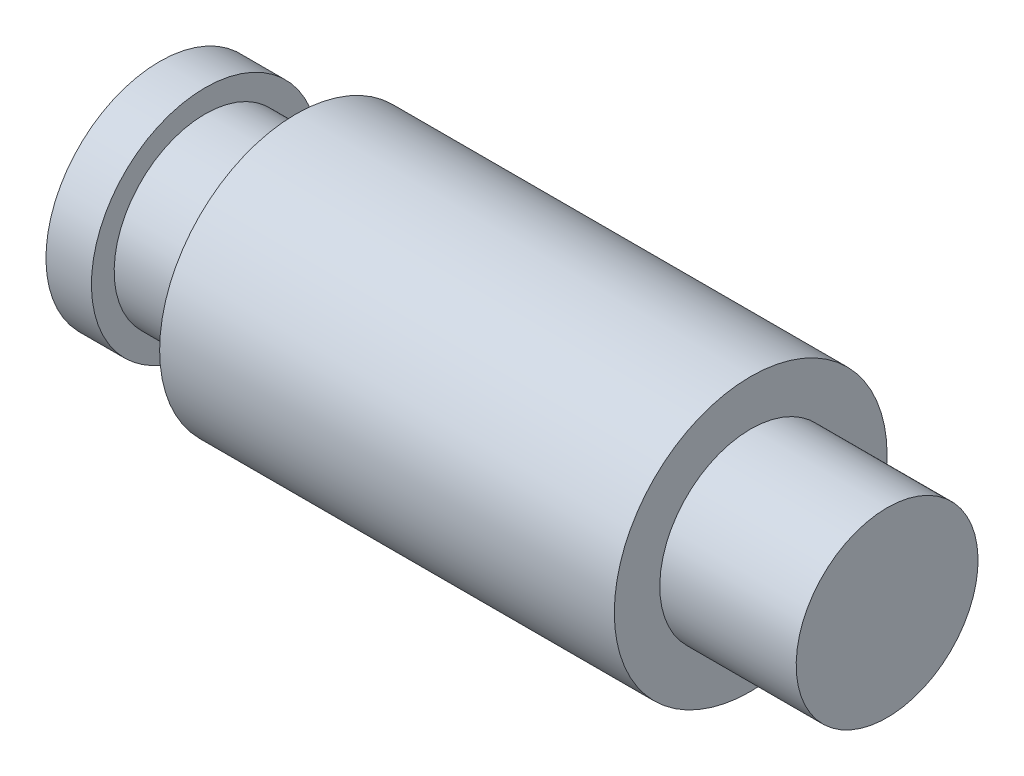
from build123d import *


with BuildPart() as part:
    # Esquisse1 → Révolution1 (revolve)
    with BuildSketch(Plane.XY):
        Polygon((0, 0), (0, 2.5), (1, 2.5), (1, 2), (3, 2), (3, 3), (13, 3), (13, 2), (16, 2), (16, 0), align=None)
    revolve(axis=Axis((16, 0, 0), (-1, 0, 0)))


solid = part.part
